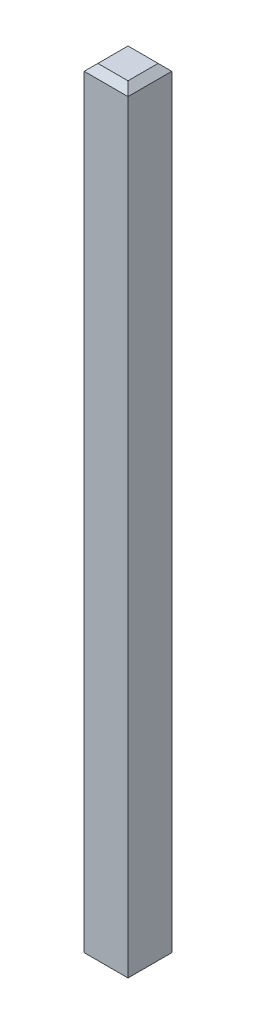
from build123d import *

# Parameters (mm, degrees)
SKETCH_1_W     = 0.64
SKETCH_1_H     = 0.64
CHAMFER_1_SIZE = 0.1


with BuildPart() as part:
    # По траектории1: sweep along a path in Эскиз2
    with BuildLine(Plane.XY) as sweep_1_path:
        Line((0, 0), (0, 11.35))
    # Эскиз1 → По траектории1 (sweep)
    with BuildSketch(Plane(origin=(0, 0, 0), x_dir=(1, 0, 0), z_dir=(0, 1, 0))):
        Rectangle(SKETCH_1_W, SKETCH_1_H)
    sweep(path=sweep_1_path.line)

    # Фаска1
    chamfer_1_edges = [part.edges().sort_by_distance(p)[0] for p in [
        (-0.32, 11.35, 0),
        (0, 11.35, 0.32),
        (0.32, 11.35, 0),
        (0, 0, 0.32),
        (-0.32, 0, 0),
        (0, 0, -0.32),
        (0.32, 0, 0),
        (0, 11.35, -0.32),
    ]]
    chamfer(chamfer_1_edges, length=CHAMFER_1_SIZE)


solid = part.part
